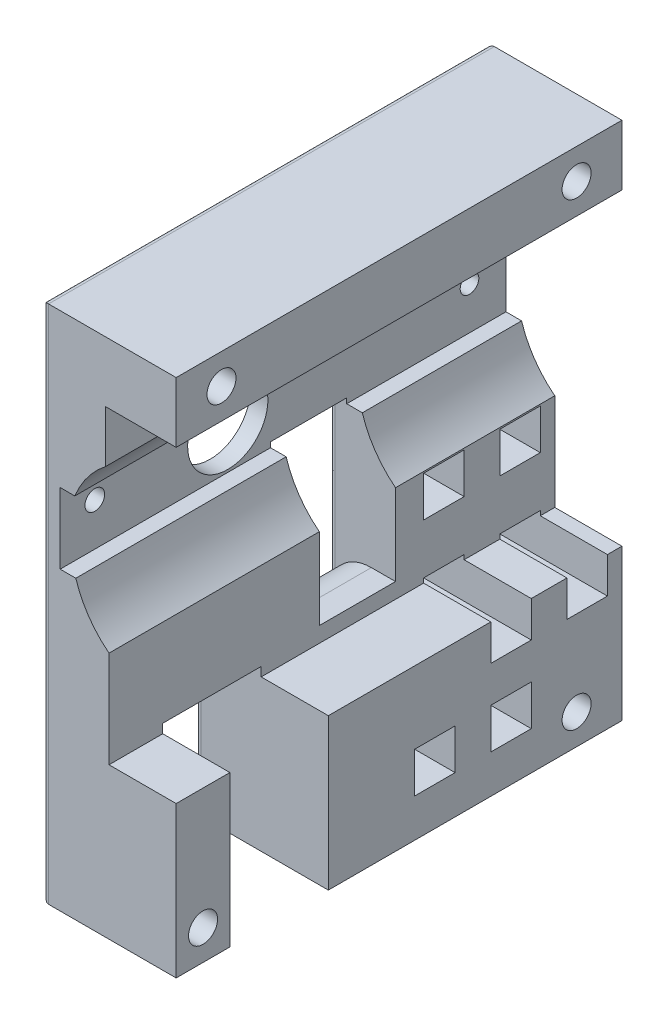
from build123d import *

# Parameters (mm, degrees)
PROFILEEXTRUDE_DEPTH    = 73.76
HOSEWINDOW_W            = 16.29
HOSEWINDOW_H            = 26.5
HOSEWINDOWCUT_DEPTH     = 23.11
CAGESCREWS_R            = 2.4
CAGESCREWSCUT_DEPTH     = 23.11
AXLEHOLECUT_DEPTH       = 23.11
SETSCREWHOLES_R         = 1.539432213
SETSCREWHOLES_R_2       = 1.628953018
SETSCREWHOLESCUT_DEPTH  = 23.11
VELOCITYWINDOW_W        = 12.61
VELOCITYWINDOW_H        = 22.29
VELOCITYWINDOWCUT_DEPTH = 23.11
FILLET3_R               = 7
TRIGGERRACKSLOTCUT_W    = 6.7
TRIGGERRACKSLOTCUT_H    = 6.7
RACKSLOTCUT_DEPTH       = 23.11
FILLET4_R               = 1


with BuildPart() as part:
    # Profile → ProfileExtrude (new body)
    with BuildSketch(Plane.XY):
        with BuildLine():
            Line((10.261269376, -54.194713793), (10.261269376, -29.194713793))
            Line((10.261269376, -29.194713793), (-0.848730624, -29.194713793))
            Line((-0.848730624, -29.194713793), (-0.848730624, -13.194713793))
            ThreePointArc((-0.848730624, -13.194713793), (-4.204080189, -9.618555822), (-6.340730624, -5.204713793))
            Line((-6.340730624, -5.204713793), (-8.928730624, -5.204713793))
            Line((-8.928730624, -5.204713793), (-8.928730624, 6.495286207))
            Line((-8.928730624, 6.495286207), (-6.509650624, 6.495286207))
            ThreePointArc((-6.509650624, 6.495286207), (-4.40075771, 10.230064383), (-1.388730624, 13.283536207))
            Line((-1.388730624, 13.283536207), (-1.388730624, 21.845286207))
            Line((-1.388730624, 21.845286207), (10.261269376, 21.845286207))
            Line((10.261269376, 21.845286207), (10.261269376, 31.845286207))
            Line((10.261269376, 31.845286207), (-11.848730624, 31.845286207))
            Line((-11.848730624, 31.845286207), (-11.848730624, -54.194713793))
            Line((-11.848730624, -54.194713793), (10.261269376, -54.194713793))
        make_face()
    extrude(amount=PROFILEEXTRUDE_DEPTH)

    # HoseWindow → HoseWindowCut (cut, through all)
    with BuildSketch(Plane.ZY.offset(11.848730624)):
        with Locations((56.725, -40.944713793)):
            Rectangle(HOSEWINDOW_W, HOSEWINDOW_H)
    extrude(amount=-HOSEWINDOWCUT_DEPTH, mode=Mode.SUBTRACT)

    # CageScrews → CageScrewsCut (cut, through all)
    with BuildSketch(Plane.ZY.offset(11.848730624)):
        with Locations((7.5, 26.845286207)):
            Circle(CAGESCREWS_R)
        with Locations((66.26, 26.845286207)):
            Circle(CAGESCREWS_R)
        with Locations((7.5, -49.194713793)):
            Circle(CAGESCREWS_R)
        with Locations((69.31, -49.194713793)):
            Circle(CAGESCREWS_R)
    extrude(amount=-CAGESCREWSCUT_DEPTH, mode=Mode.SUBTRACT)

    # AxleHole → AxleHoleCut (cut, through all)
    with BuildSketch(Plane.ZY.offset(11.848730624)):
        with BuildLine():
            Line((47.361, 8.359497151), (47.361, 6.740497151))
            Line((47.361, 6.740497151), (44.699, 6.740497151))
            Line((44.699, 6.740497151), (44.699, 8.359497151))
            ThreePointArc((44.699, 8.359497151), (46.03, -4.783713793), (47.361, 8.359497151))
        make_face()
    extrude(amount=-AXLEHOLECUT_DEPTH, mode=Mode.SUBTRACT)

    # SetScrewHoles → SetScrewHolesCut (cut, through all)
    with BuildSketch(Plane.ZY.offset(11.848730624)):
        with Locations((6.03, 1.855286207)):
            Circle(SETSCREWHOLES_R)
        with Locations((68.03, 1.855286207)):
            Circle(SETSCREWHOLES_R_2)
    extrude(amount=-SETSCREWHOLESCUT_DEPTH, mode=Mode.SUBTRACT)

    # VelocityWindow → VelocityWindowCut (cut, through all)
    with BuildSketch(Plane.ZY.offset(11.848730624)):
        with Locations((32.655, -15.499713793)):
            Rectangle(VELOCITYWINDOW_W, VELOCITYWINDOW_H)
    extrude(amount=-VELOCITYWINDOWCUT_DEPTH, mode=Mode.SUBTRACT)

    # Fillet3
    fillet3_edges = [part.edges().sort_by_distance(p)[0] for p in [
        (-11.848730624, -26.644713793, 32.655),
    ]]
    fillet(fillet3_edges, radius=FILLET3_R)

    # TriggerRackSlotCut → RackSlotCut (cut, through all)
    with BuildSketch(Plane.ZY.offset(11.848730624)):
        with Locations((18.35, -44.494713793)):
            Rectangle(TRIGGERRACKSLOTCUT_W, TRIGGERRACKSLOTCUT_H)
        with Locations((30.95, -44.494713793)):
            Rectangle(TRIGGERRACKSLOTCUT_W, TRIGGERRACKSLOTCUT_H)
        with Locations((5.75, -31.794713793)):
            Rectangle(TRIGGERRACKSLOTCUT_W, TRIGGERRACKSLOTCUT_H)
        with Locations((18.35, -31.794713793)):
            Rectangle(TRIGGERRACKSLOTCUT_W, TRIGGERRACKSLOTCUT_H)
        with Locations((5.75, -16.794713793)):
            Rectangle(TRIGGERRACKSLOTCUT_W, TRIGGERRACKSLOTCUT_H)
        with Locations((18.35, -16.794713793)):
            Rectangle(TRIGGERRACKSLOTCUT_W, TRIGGERRACKSLOTCUT_H)
    extrude(amount=-RACKSLOTCUT_DEPTH, mode=Mode.SUBTRACT)

    # Fillet4
    fillet4_edges = [part.edges().sort_by_distance(p)[0] for p in [
        (-11.848730624, -11.174713793, 73.76),
        (-11.848730624, -18.999713793, 26.35),
        (-11.848730624, -18.999713793, 38.96),
        (-11.848730624, -4.354713793, 32.655),
        (-11.848730624, -44.494713793, 15),
        (-11.848730624, -47.844713793, 18.35),
        (-11.848730624, -44.494713793, 21.7),
        (-11.848730624, -41.144713793, 18.35),
        (-11.848730624, -11.174713793, 0),
        (-11.848730624, -44.494713793, 27.6),
        (-11.848730624, -47.844713793, 30.95),
        (-11.848730624, -44.494713793, 34.3),
        (-11.848730624, -41.144713793, 30.95),
        (-11.848730624, -31.794713793, 2.4),
        (-11.848730624, -35.144713793, 5.75),
        (-11.848730624, -31.794713793, 9.1),
        (-11.848730624, -28.444713793, 5.75),
        (-11.848730624, -31.794713793, 15),
        (-11.848730624, -35.144713793, 18.35),
        (-11.848730624, -31.794713793, 21.7),
        (-11.848730624, -28.444713793, 18.35),
        (-11.848730624, -16.794713793, 2.4),
        (-11.848730624, -20.144713793, 5.75),
        (-11.848730624, -16.794713793, 9.1),
        (-11.848730624, -13.444713793, 5.75),
        (-11.848730624, -54.194713793, 69.315),
        (-11.848730624, 31.845286207, 36.88),
        (-11.848730624, -16.794713793, 15),
        (-11.848730624, -20.144713793, 18.35),
        (-11.848730624, -16.794713793, 21.7),
        (-11.848730624, -13.444713793, 18.35),
        (-11.848730624, -54.194713793, 24.29),
        (-11.848730624, -40.944713793, 64.87),
        (-11.848730624, -27.694713793, 56.725),
        (-11.848730624, -40.944713793, 48.58),
    ]]
    fillet(fillet4_edges, radius=FILLET4_R)


solid = part.part
